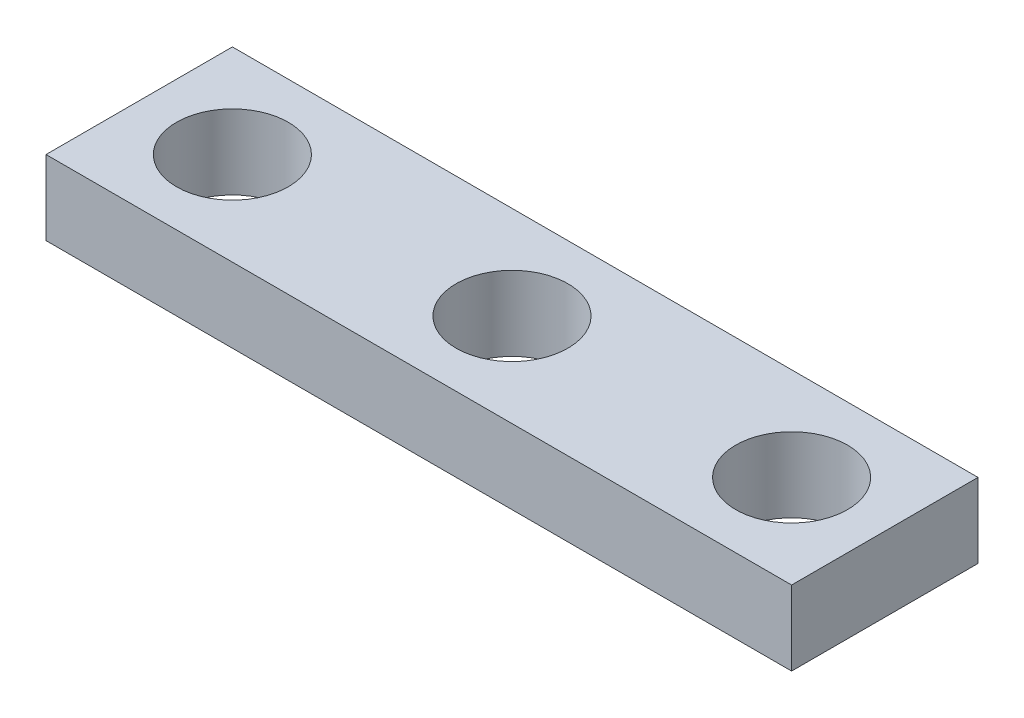
from build123d import *

# Parameters (mm, degrees)
SKETCH1_W           = 25.4
SKETCH1_H           = 6.35
SKETCH1_R           = 1.905
BOSS_EXTRUDE1_DEPTH = 2.54


with BuildPart() as part:
    # Sketch1 → Boss-Extrude1 (new body)
    with BuildSketch(Plane(origin=(0, 0, 0), x_dir=(1, 0, 0), z_dir=(0, 1, 0))):
        Rectangle(SKETCH1_W, SKETCH1_H)
        with Locations((-9.525, 0)):
            Circle(SKETCH1_R, mode=Mode.SUBTRACT)
        with Locations((9.525, 0)):
            Circle(SKETCH1_R, mode=Mode.SUBTRACT)
        Circle(SKETCH1_R, mode=Mode.SUBTRACT)
    extrude(amount=BOSS_EXTRUDE1_DEPTH)


solid = part.part
